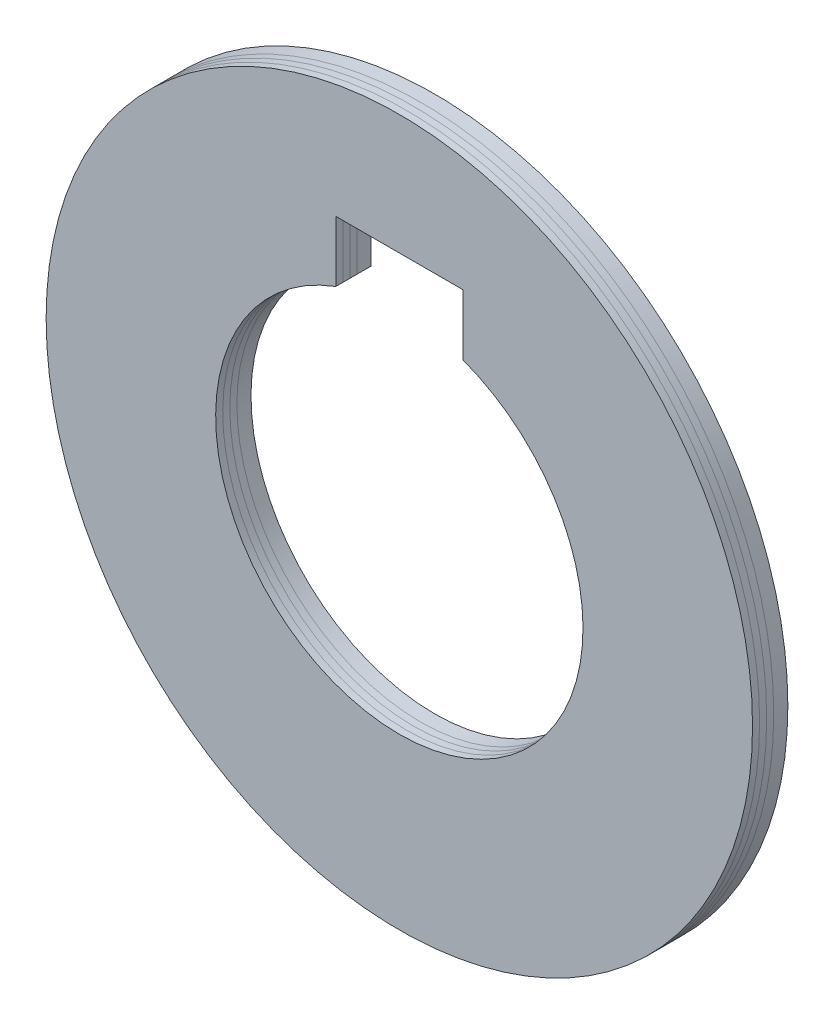
from build123d import *

# Parameters (mm, degrees)
SKETCH_1_R                       = 25
EXTRUDE_1_DEPTH                  = 2.5
SPLIT_BODIES_1_SURFACE_3_1_BACK  = 71.755
SPLIT_BODIES_1_SURFACE_3_1_DEPTH = 143.51
SPLIT_BODIES_1_SURFACE_3_2_BACK  = 71.755
SPLIT_BODIES_1_SURFACE_3_2_DEPTH = 143.51
SPLIT_BODIES_1_SURFACE_4_3_BACK  = 71.755
SPLIT_BODIES_1_SURFACE_4_3_DEPTH = 143.51
SPLIT_BODIES_1_SURFACE_4_4_BACK  = 71.755
SPLIT_BODIES_1_SURFACE_4_4_DEPTH = 143.51
SPLIT_BODIES_1_SURFACE_5_5_BACK  = 71.755
SPLIT_BODIES_1_SURFACE_5_5_DEPTH = 143.51
SPLIT_BODIES_1_SURFACE_5_6_BACK  = 71.755
SPLIT_BODIES_1_SURFACE_5_6_DEPTH = 143.51


with BuildPart() as part:
    # Эскиз1 → Вытянуть1 (new body)
    with BuildSketch(Plane.XY):
        Circle(SKETCH_1_R)
        with BuildLine():
            Line((-4.5, 16.5), (4.5, 16.5))
            Line((4.5, 16.5), (4.5, 12.196310918))
            ThreePointArc((4.5, 12.196310918), (0, -13), (-4.5, 12.196310918))
            Line((-4.5, 12.196310918), (-4.5, 16.5))
        make_face(mode=Mode.SUBTRACT)
    extrude(amount=EXTRUDE_1_DEPTH)


with BuildPart() as body_2_3:
    # Split Bodies 1 3: the piece behind the surface
    add(part.part)
    # Split Bodies 1 surface 3: a surface, the sketch's curves swept straight by 143.51 mm
    with BuildLine(Plane(origin=(0, 0, 0), x_dir=(1, 0, 0), z_dir=(0, 1, 0)).offset(-SPLIT_BODIES_1_SURFACE_3_1_BACK), mode=Mode.PRIVATE) as split_bodies_1_surface_3_1_path:
        Line((-25, -1), (25, -1))
    split_bodies_1_surface_3_1 = Shell.extrude(split_bodies_1_surface_3_1_path.wire(), (0 * SPLIT_BODIES_1_SURFACE_3_1_DEPTH, 1 * SPLIT_BODIES_1_SURFACE_3_1_DEPTH, 0 * SPLIT_BODIES_1_SURFACE_3_1_DEPTH))
    split(bisect_by=split_bodies_1_surface_3_1, keep=Keep.BOTTOM)


with BuildPart() as part_1:
    add(part.part)

    # Split Bodies 1 3: split by a surface, the side it looks to stays
    # Split Bodies 1 surface 3: a surface, the sketch's curves swept straight by 143.51 mm
    with BuildLine(Plane(origin=(0, 0, 0), x_dir=(1, 0, 0), z_dir=(0, 1, 0)).offset(-SPLIT_BODIES_1_SURFACE_3_2_BACK), mode=Mode.PRIVATE) as split_bodies_1_surface_3_2_path:
        Line((-25, -1), (25, -1))
    split_bodies_1_surface_3_2 = Shell.extrude(split_bodies_1_surface_3_2_path.wire(), (0 * SPLIT_BODIES_1_SURFACE_3_2_DEPTH, 1 * SPLIT_BODIES_1_SURFACE_3_2_DEPTH, 0 * SPLIT_BODIES_1_SURFACE_3_2_DEPTH))
    split(bisect_by=split_bodies_1_surface_3_2, keep=Keep.TOP)


with BuildPart() as body_3:
    # Split Bodies 1 4 body 2 3: the piece behind the surface
    add(body_2_3.part)
    # Split Bodies 1 surface 4: a surface, the sketch's curves swept straight by 143.51 mm
    with BuildLine(Plane(origin=(0, 0, 0), x_dir=(1, 0, 0), z_dir=(0, 1, 0)).offset(-SPLIT_BODIES_1_SURFACE_4_3_BACK), mode=Mode.PRIVATE) as split_bodies_1_surface_4_3_path:
        Line((-25, -1.5), (25, -1.5))
    split_bodies_1_surface_4_3 = Shell.extrude(split_bodies_1_surface_4_3_path.wire(), (0 * SPLIT_BODIES_1_SURFACE_4_3_DEPTH, 1 * SPLIT_BODIES_1_SURFACE_4_3_DEPTH, 0 * SPLIT_BODIES_1_SURFACE_4_3_DEPTH))
    split(bisect_by=split_bodies_1_surface_4_3, keep=Keep.BOTTOM)


with BuildPart() as body_2_3_1:
    add(body_2_3.part)

    # Split Bodies 1 4 body 2 3: split by a surface, the side it looks to stays
    # Split Bodies 1 surface 4: a surface, the sketch's curves swept straight by 143.51 mm
    with BuildLine(Plane(origin=(0, 0, 0), x_dir=(1, 0, 0), z_dir=(0, 1, 0)).offset(-SPLIT_BODIES_1_SURFACE_4_4_BACK), mode=Mode.PRIVATE) as split_bodies_1_surface_4_4_path:
        Line((-25, -1.5), (25, -1.5))
    split_bodies_1_surface_4_4 = Shell.extrude(split_bodies_1_surface_4_4_path.wire(), (0 * SPLIT_BODIES_1_SURFACE_4_4_DEPTH, 1 * SPLIT_BODIES_1_SURFACE_4_4_DEPTH, 0 * SPLIT_BODIES_1_SURFACE_4_4_DEPTH))
    split(bisect_by=split_bodies_1_surface_4_4, keep=Keep.TOP)


with BuildPart() as body_4:
    # Split Bodies 1 5 body 3: the piece behind the surface
    add(body_3.part)
    # Split Bodies 1 surface 5: a surface, the sketch's curves swept straight by 143.51 mm
    with BuildLine(Plane(origin=(0, 0, 0), x_dir=(1, 0, 0), z_dir=(0, 1, 0)).offset(-SPLIT_BODIES_1_SURFACE_5_5_BACK), mode=Mode.PRIVATE) as split_bodies_1_surface_5_5_path:
        Line((-25, -2), (25, -2))
    split_bodies_1_surface_5_5 = Shell.extrude(split_bodies_1_surface_5_5_path.wire(), (0 * SPLIT_BODIES_1_SURFACE_5_5_DEPTH, 1 * SPLIT_BODIES_1_SURFACE_5_5_DEPTH, 0 * SPLIT_BODIES_1_SURFACE_5_5_DEPTH))
    split(bisect_by=split_bodies_1_surface_5_5, keep=Keep.BOTTOM)


with BuildPart() as body_3_1:
    add(body_3.part)

    # Split Bodies 1 5 body 3: split by a surface, the side it looks to stays
    # Split Bodies 1 surface 5: a surface, the sketch's curves swept straight by 143.51 mm
    with BuildLine(Plane(origin=(0, 0, 0), x_dir=(1, 0, 0), z_dir=(0, 1, 0)).offset(-SPLIT_BODIES_1_SURFACE_5_6_BACK), mode=Mode.PRIVATE) as split_bodies_1_surface_5_6_path:
        Line((-25, -2), (25, -2))
    split_bodies_1_surface_5_6 = Shell.extrude(split_bodies_1_surface_5_6_path.wire(), (0 * SPLIT_BODIES_1_SURFACE_5_6_DEPTH, 1 * SPLIT_BODIES_1_SURFACE_5_6_DEPTH, 0 * SPLIT_BODIES_1_SURFACE_5_6_DEPTH))
    split(bisect_by=split_bodies_1_surface_5_6, keep=Keep.TOP)


solid = Compound([part_1.part, body_2_3_1.part, body_4.part, body_3_1.part])
